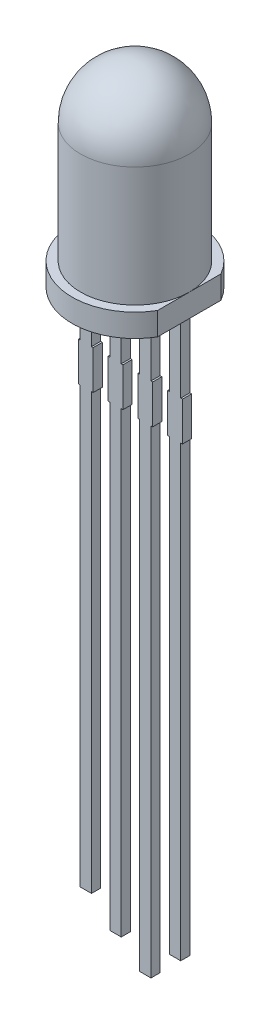
from build123d import *

# Parameters (mm, degrees)
SKETCH2_W           = 0.5
SKETCH2_H           = 24.3
SKETCH2_H_2         = 25.6
SKETCH2_H_3         = 24.7
SKETCH2_H_4         = 23.7
SKETCH2_W_2         = 0.65
SKETCH2_H_5         = 1.7
BOSS_EXTRUDE1_DEPTH = 0.2
CUT_EXTRUDE1_DEPTH  = 27.6


with BuildPart() as part:
    # Sketch1 → Revolve1 (revolve)
    with BuildSketch(Plane.XY):
        with BuildLine():
            Line((0, 0), (2.75, 0))
            Line((2.75, 0), (2.75, 1))
            Line((2.75, 1), (2.375, 1))
            Line((2.375, 1), (2.375, 6.225))
            ThreePointArc((2.375, 6.225), (1.679378605, 7.904378605), (0, 8.6))
            Line((0, 8.6), (0, 0))
        make_face()
    revolve(axis=Axis((0, 0, 0), (0, -1, 0)))

    # Sketch2 → Boss-Extrude1 (add, symmetric)
    with BuildSketch(Plane.XY):
        with Locations((1.95, -12.15)):
            Rectangle(SKETCH2_W, SKETCH2_H)
        with Locations((0.65, -12.8)):
            Rectangle(SKETCH2_W, SKETCH2_H_2)
        with Locations((-0.65, -12.35)):
            Rectangle(SKETCH2_W, SKETCH2_H_3)
        with Locations((-1.95, -11.85)):
            Rectangle(SKETCH2_W, SKETCH2_H_4)
        with Locations((-1.95, -3.85)):
            Rectangle(SKETCH2_W_2, SKETCH2_H_5)
        with Locations((-0.65, -3.85)):
            Rectangle(SKETCH2_W_2, SKETCH2_H_5)
        with Locations((0.65, -3.85)):
            Rectangle(SKETCH2_W_2, SKETCH2_H_5)
        with Locations((1.95, -3.85)):
            Rectangle(SKETCH2_W_2, SKETCH2_H_5)
    extrude(amount=BOSS_EXTRUDE1_DEPTH, both=True)

    # Sketch3 → Cut-Extrude1 (cut, through all)
    with BuildSketch(Plane(origin=(0, 1, 0), x_dir=(1, 0, 0), z_dir=(0, 1, 0))):
        Polygon((2.375, 24.558218042), (2.375, 1.386317063), (2.375, -1.386317063), (2.375, -24.558218042), (48.718801957, -24.558218042), (48.718801957, 24.558218042), align=None)
    extrude(amount=-CUT_EXTRUDE1_DEPTH, mode=Mode.SUBTRACT)


solid = part.part
